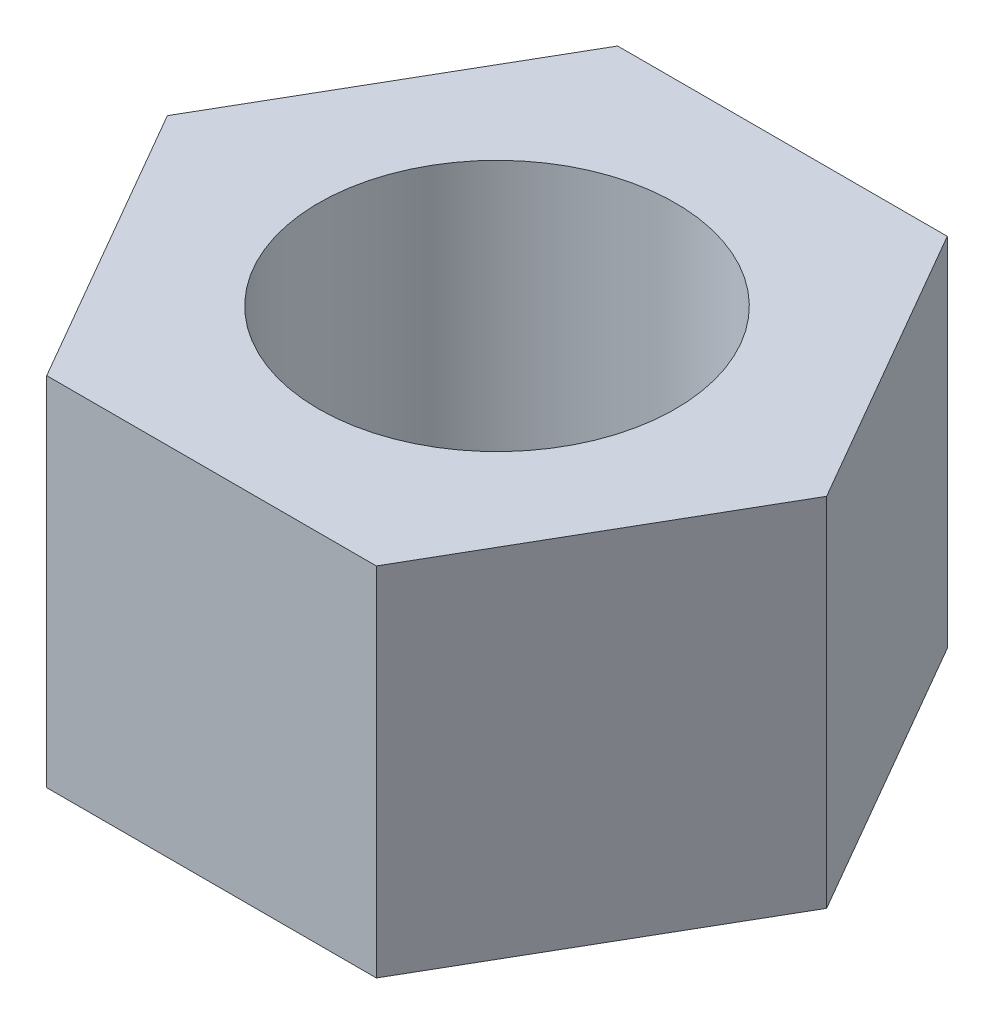
from build123d import *

# Parameters (mm, degrees)
BOSS_EXTRUDE1_DEPTH = 5
SKETCH3_R           = 2.5
CUT_EXTRUDE1_DEPTH  = 6


with BuildPart() as part:
    # Sketch2 → Boss-Extrude1 (new body)
    with BuildSketch(Plane(origin=(0, 0, 0), x_dir=(1, 0, 0), z_dir=(0, 1, 0))):
        Polygon((4.618802154, 0), (2.309401077, 4), (-2.309401077, 4), (-4.618802154, 0), (-2.309401077, -4), (2.309401077, -4), align=None)
    extrude(amount=BOSS_EXTRUDE1_DEPTH)

    # Sketch3 → Cut-Extrude1 (cut, through all)
    with BuildSketch(Plane(origin=(0, 5, 0), x_dir=(1, 0, 0), z_dir=(0, 1, 0))):
        Circle(SKETCH3_R)
    extrude(amount=-CUT_EXTRUDE1_DEPTH, mode=Mode.SUBTRACT)


solid = part.part
